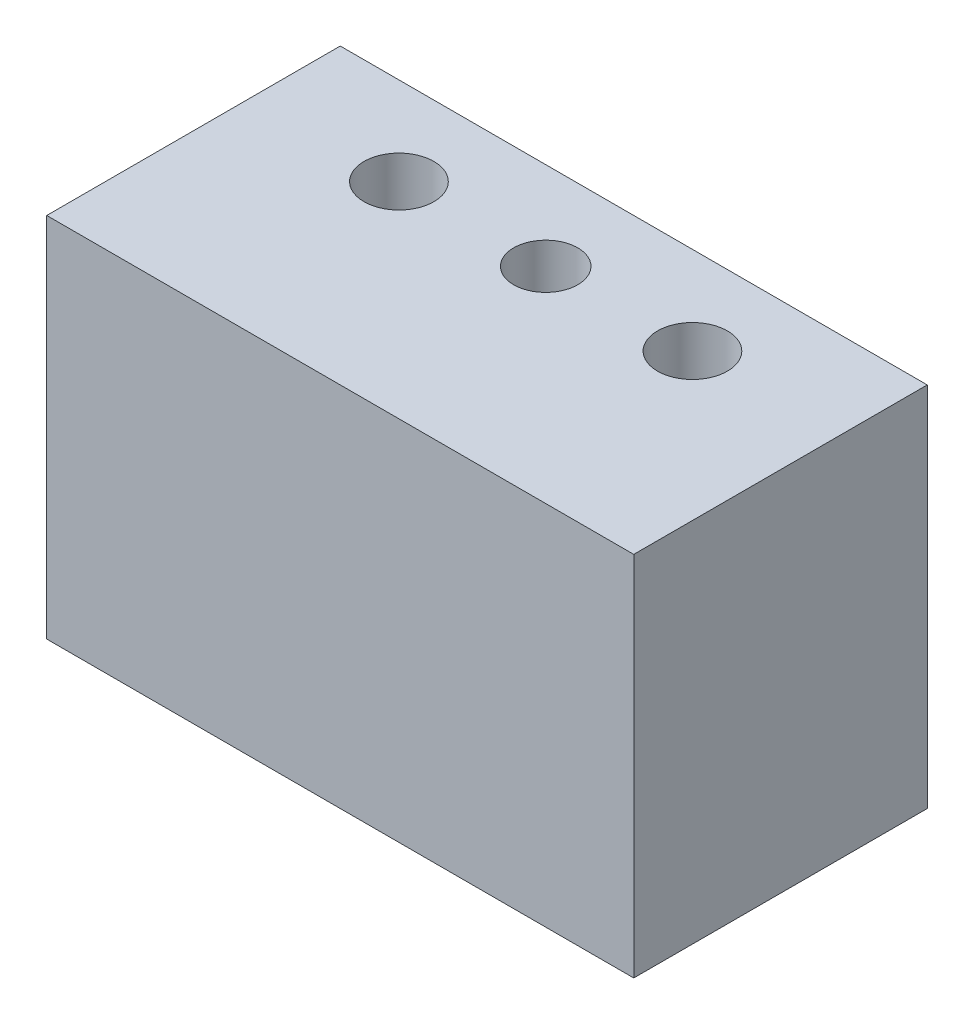
from build123d import *

# Parameters (mm, degrees)
SKETCH1_W                        = 40
SKETCH1_H                        = 20
SKETCH1_R                        = 2.38
BOSS_EXTRUDE1_DEPTH              = 25
F_11_64_0_17188_DIAMETER_HOLE1_D = 4.365752


with BuildPart() as part:
    # Sketch1 → Boss-Extrude1 (new body)
    with BuildSketch(Plane(origin=(0, 0, 0), x_dir=(1, 0, 0), z_dir=(0, 1, 0))):
        with Locations((20, 10)):
            Rectangle(SKETCH1_W, SKETCH1_H)
        with Locations(Location((10, 14, 0), (0, 0, 270))):  # turned: the seam where the file's is
            Circle(SKETCH1_R, mode=Mode.SUBTRACT)
        with Locations(Location((30, 14, 0), (0, 0, 270))):  # turned: the seam where the file's is
            Circle(SKETCH1_R, mode=Mode.SUBTRACT)
    extrude(amount=BOSS_EXTRUDE1_DEPTH)

    # 11/64 (0.17188) Diameter Hole1 (through all)
    with Locations(Plane(origin=(0, 25, 0), x_dir=(1, 0, 0), z_dir=(0, 1, 0))):
        with Locations((20, 14)):
            Hole(F_11_64_0_17188_DIAMETER_HOLE1_D / 2)


solid = part.part
